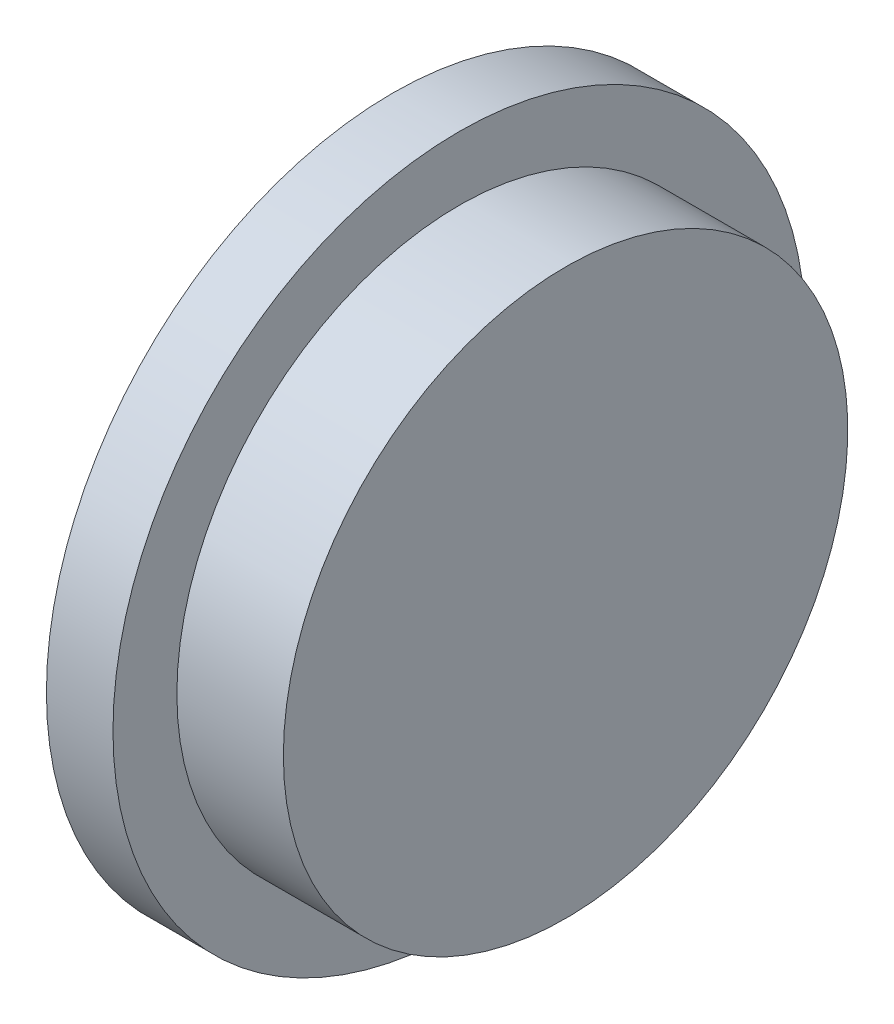
from build123d import *


with BuildPart() as part:
    # Skica1 → Rotovat1 (revolve)
    with BuildSketch(Plane.XY):
        Polygon((0, 0), (0, 2.8), (2, 2.8), (2, 6.5), (3.25, 6.5), (3.25, 5.3), (5.25, 5.3), (5.25, 0), align=None)
    revolve(axis=Axis((-1.671428571, 0, 0), (1, 0, 0)))


solid = part.part
